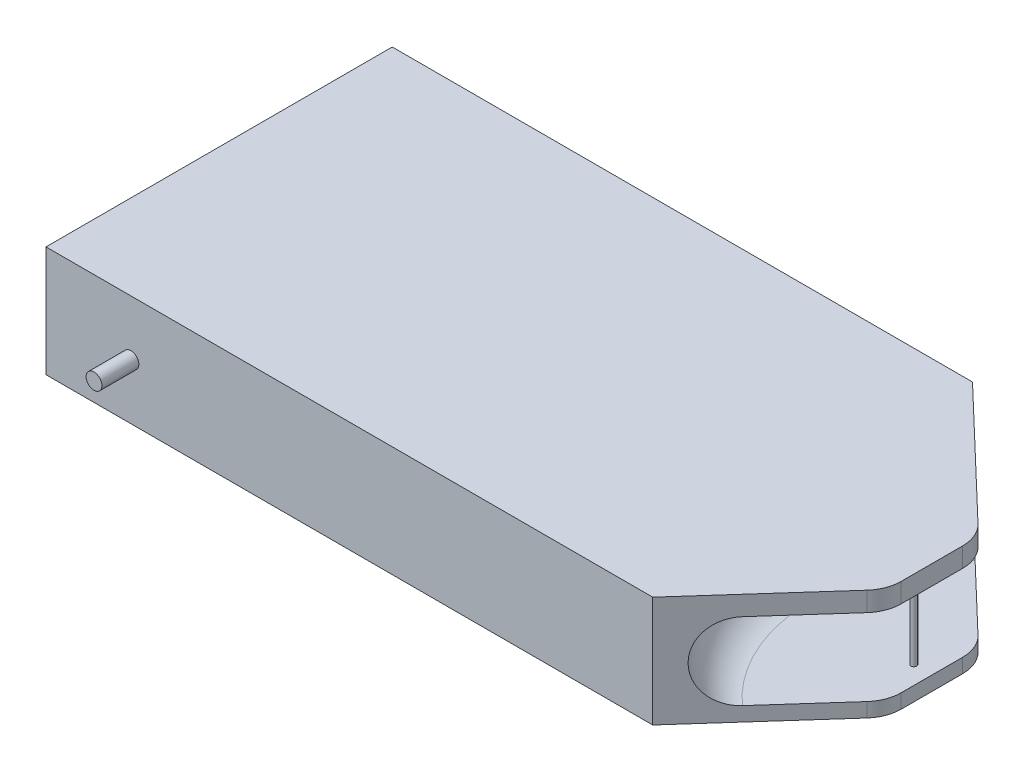
from build123d import *

# Parameters (mm, degrees)
BOSS_EXTRUDE1_DEPTH      = 30
SKETCH3_R                = 2.146244949
BOSS_EXTRUDE2_DEPTH      = 10
BOSS_EXTRUDE2_DEPTH_BACK = 104
SKETCH4_W                = 62.472603167
SKETCH4_H                = 24.76734243
CUT_EXTRUDE1_DEPTH       = 31
FILLET1_R                = 10
SKETCH5_R                = 0.76292284
BOSS_EXTRUDE3_DEPTH      = 30
SKETCH8_W                = 88.333137
SKETCH8_H                = 25.902143048
CUT_EXTRUDE2_DEPTH       = 5
SKETCH9_R                = 0.25
BOSS_EXTRUDE4_DEPTH      = 90


with BuildPart() as part:
    # Sketch1 → Boss-Extrude1 (new body)
    with BuildSketch(Plane(origin=(0, 0, 0), x_dir=(1, 0, 0), z_dir=(0, 1, 0))):
        Polygon((-80.330769327, 39.448145651), (-80.330769327, -54.366717098), (84.060412188, -54.366717098), (125.94717048, -7.459285723), (76.88802207, 39.448145651), align=None)
    extrude(amount=BOSS_EXTRUDE1_DEPTH)

    # Sketch2 → Cut-Revolve2 (revolve, cut)
    with BuildSketch(Plane(origin=(73.778167937, 0, 65.881422133), x_dir=(0.666061097, 0, -0.745897188), z_dir=(0.745897188, 0, 0.666061097))):
        with BuildLine():
            Line((32.647209403, 24.725169295), (66.605654017, 24.725169295))
            ThreePointArc((66.605654017, 24.725169295), (77.035151749, 14.295671563), (66.605654017, 3.866173832))
            Line((66.605654017, 3.866173832), (32.647209403, 3.866173832))
            ThreePointArc((32.647209403, 3.866173832), (22.217711672, 14.295671563), (32.647209403, 24.725169295))
        make_face()
    revolve(axis=Axis((125.94717048, 30, 7.459285723), (0, -1, 0)), mode=Mode.SUBTRACT)

    # Sketch3 → Boss-Extrude2 (add, two sides)
    with BuildSketch(Plane.XY.offset(54.366717098)) as boss_extrude2_sk:
        with Locations((-57.321321229, 15)):
            Circle(SKETCH3_R)
    extrude(amount=BOSS_EXTRUDE2_DEPTH)
    extrude(boss_extrude2_sk.sketch, amount=-BOSS_EXTRUDE2_DEPTH_BACK)

    # Sketch4 → Cut-Extrude1 (cut, through all)
    with BuildSketch(Plane(origin=(0, 30, 0), x_dir=(1, 0, 0), z_dir=(0, 1, 0))):
        with Locations((145.25317231, -8.435915945)):
            Rectangle(SKETCH4_W, SKETCH4_H)
    extrude(amount=-CUT_EXTRUDE1_DEPTH, mode=Mode.SUBTRACT)

    # Fillet1
    fillet1_edges = [part.edges().sort_by_distance(p)[0] for p in [
        (114.016870726, 1.933086916, 20.81958716),
        (114.016870726, 27.362584647, 20.81958716),
        (114.016870726, 1.933086916, -3.94775527),
        (114.016870726, 27.362584647, -3.94775527),
    ]]
    fillet(fillet1_edges, radius=FILLET1_R)

    # Sketch5 → Boss-Extrude3 (add)
    with BuildSketch(Plane(origin=(0, 30, 0), x_dir=(1, 0, 0), z_dir=(0, 1, 0))):
        with Locations((109.099187599, -8.665449149)):
            Circle(SKETCH5_R)
    extrude(amount=-BOSS_EXTRUDE3_DEPTH)

    # Sketch8 → Cut-Extrude2 (cut)
    with BuildSketch(Plane.ZY.offset(80.330769327)):
        with Locations((7.459285723, 15)):
            Rectangle(SKETCH8_W, SKETCH8_H)
    extrude(amount=-CUT_EXTRUDE2_DEPTH, mode=Mode.SUBTRACT)

    # Sketch9 → Boss-Extrude4 (add)
    with BuildSketch(Plane(origin=(0, 0, 51.625854223), x_dir=(-1, 0, 0), z_dir=(0, 0, -1))):
        with Locations((79.909462448, 27.17643451)):
            Circle(SKETCH9_R)
    extrude(amount=BOSS_EXTRUDE4_DEPTH)


solid = part.part
